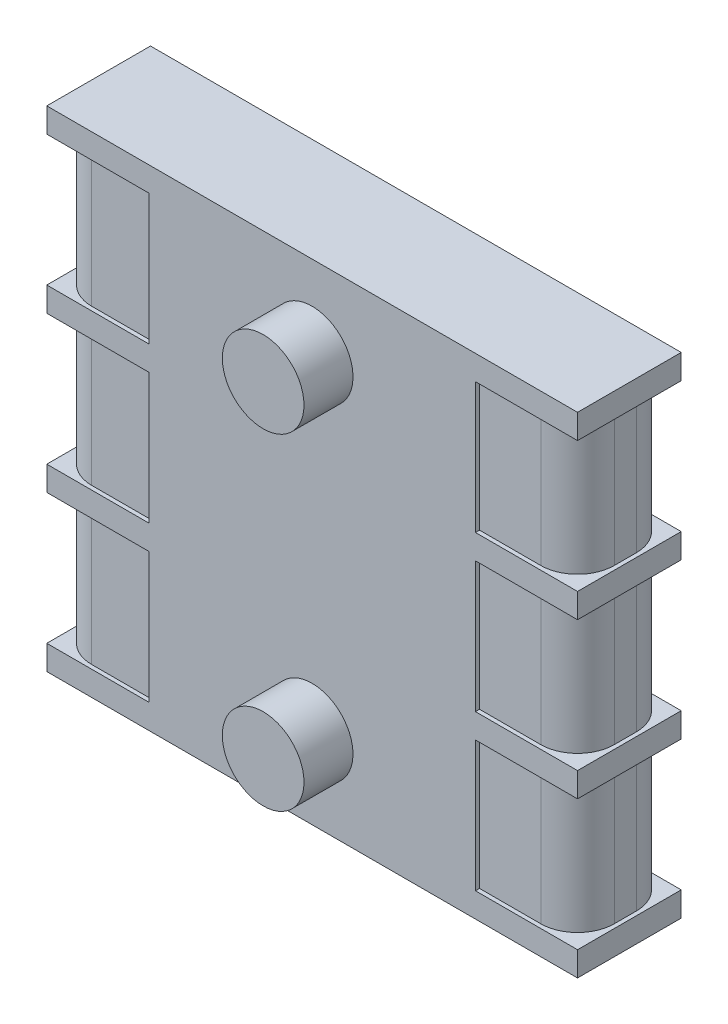
from build123d import *

# Parameters (mm, degrees)
SKETCH1_W           = 6.5
SKETCH1_H           = 1.27
BOSS_EXTRUDE1_DEPTH = 0.3
BOSS_EXTRUDE2_DEPTH = 1.6
BOSS_EXTRUDE3_START = 1.9
SKETCH1_2_W         = 6.5
SKETCH1_2_H         = 1.27
BOSS_EXTRUDE3_DEPTH = 0.3
BOSS_EXTRUDE4_START = 1.9
BOSS_EXTRUDE4_DEPTH = 1.6
BOSS_EXTRUDE5_START = 3.8
SKETCH1_3_W         = 6.5
SKETCH1_3_H         = 1.27
BOSS_EXTRUDE5_DEPTH = 0.3
BOSS_EXTRUDE6_START = 3.8
BOSS_EXTRUDE6_DEPTH = 1.6
BOSS_EXTRUDE7_START = 5.7
SKETCH1_4_W         = 6.5
SKETCH1_4_H         = 1.27
BOSS_EXTRUDE7_DEPTH = 0.3
SKETCH3_W           = 4
SKETCH3_H           = 5.4
BOSS_EXTRUDE8_DEPTH = 0.2
SKETCH4_R           = 0.5
BOSS_EXTRUDE9_DEPTH = 0.6


with BuildPart() as part:
    # Sketch1 → Boss-Extrude1 (new body)
    with BuildSketch(Plane(origin=(0, 0, 0), x_dir=(1, 0, 0), z_dir=(0, 1, 0))):
        with Locations((3.25, 0.635)):
            Rectangle(SKETCH1_W, SKETCH1_H)
    extrude(amount=BOSS_EXTRUDE1_DEPTH)

    # Sketch2 → Boss-Extrude2 (add)
    with BuildSketch(Plane(origin=(0, 0.3, 0), x_dir=(1, 0, 0), z_dir=(0, 1, 0))):
        with BuildLine():
            Line((1.25, 0.2), (0.5, 0.2))
            ThreePointArc((0.5, 0.2), (0.287867966, 0.287867966), (0.2, 0.5))
            Line((0.2, 0.5), (0.2, 0.77))
            ThreePointArc((0.2, 0.77), (0.287867966, 0.982132034), (0.5, 1.07))
            Line((0.5, 1.07), (6, 1.07))
            ThreePointArc((6, 1.07), (6.212132034, 0.982132034), (6.3, 0.77))
            Line((6.3, 0.77), (6.3, 0.5))
            ThreePointArc((6.3, 0.5), (6.212132034, 0.287867966), (6, 0.2))
            Line((6, 0.2), (5.25, 0.2))
            Line((5.25, 0.2), (5.25, 0.05))
            Line((5.25, 0.05), (6, 0.05))
            ThreePointArc((6, 0.05), (6.318198052, 0.181801948), (6.45, 0.5))
            Line((6.45, 0.5), (6.45, 0.77))
            ThreePointArc((6.45, 0.77), (6.318198052, 1.088198052), (6, 1.22))
            Line((6, 1.22), (0.5, 1.22))
            ThreePointArc((0.5, 1.22), (0.181801948, 1.088198052), (0.05, 0.77))
            Line((0.05, 0.77), (0.05, 0.5))
            ThreePointArc((0.05, 0.5), (0.181801948, 0.181801948), (0.5, 0.05))
            Line((0.5, 0.05), (1.25, 0.05))
            Line((1.25, 0.05), (1.25, 0.2))
        make_face()
    extrude(amount=BOSS_EXTRUDE2_DEPTH)

    # Sketch1_2 → Boss-Extrude3 (add)
    with BuildSketch(Plane(origin=(0, 0, 0), x_dir=(1, 0, 0), z_dir=(0, 1, 0)).offset(BOSS_EXTRUDE3_START)):
        with Locations((3.25, 0.635)):
            Rectangle(SKETCH1_2_W, SKETCH1_2_H)
    extrude(amount=BOSS_EXTRUDE3_DEPTH)

    # Sketch2_3 → Boss-Extrude4 (add)
    with BuildSketch(Plane(origin=(0, 0.3, 0), x_dir=(1, 0, 0), z_dir=(0, 1, 0)).offset(BOSS_EXTRUDE4_START)):
        with BuildLine():
            Line((1.25, 0.2), (0.5, 0.2))
            ThreePointArc((0.5, 0.2), (0.287867966, 0.287867966), (0.2, 0.5))
            Line((0.2, 0.5), (0.2, 0.77))
            ThreePointArc((0.2, 0.77), (0.287867966, 0.982132034), (0.5, 1.07))
            Line((0.5, 1.07), (6, 1.07))
            ThreePointArc((6, 1.07), (6.212132034, 0.982132034), (6.3, 0.77))
            Line((6.3, 0.77), (6.3, 0.5))
            ThreePointArc((6.3, 0.5), (6.212132034, 0.287867966), (6, 0.2))
            Line((6, 0.2), (5.25, 0.2))
            Line((5.25, 0.2), (5.25, 0.05))
            Line((5.25, 0.05), (6, 0.05))
            ThreePointArc((6, 0.05), (6.318198052, 0.181801948), (6.45, 0.5))
            Line((6.45, 0.5), (6.45, 0.77))
            ThreePointArc((6.45, 0.77), (6.318198052, 1.088198052), (6, 1.22))
            Line((6, 1.22), (0.5, 1.22))
            ThreePointArc((0.5, 1.22), (0.181801948, 1.088198052), (0.05, 0.77))
            Line((0.05, 0.77), (0.05, 0.5))
            ThreePointArc((0.05, 0.5), (0.181801948, 0.181801948), (0.5, 0.05))
            Line((0.5, 0.05), (1.25, 0.05))
            Line((1.25, 0.05), (1.25, 0.2))
        make_face()
    extrude(amount=BOSS_EXTRUDE4_DEPTH)

    # Sketch1_3 → Boss-Extrude5 (add)
    with BuildSketch(Plane(origin=(0, 0, 0), x_dir=(1, 0, 0), z_dir=(0, 1, 0)).offset(BOSS_EXTRUDE5_START)):
        with Locations((3.25, 0.635)):
            Rectangle(SKETCH1_3_W, SKETCH1_3_H)
    extrude(amount=BOSS_EXTRUDE5_DEPTH)

    # Sketch2_4 → Boss-Extrude6 (add)
    with BuildSketch(Plane(origin=(0, 0.3, 0), x_dir=(1, 0, 0), z_dir=(0, 1, 0)).offset(BOSS_EXTRUDE6_START)):
        with BuildLine():
            Line((1.25, 0.2), (0.5, 0.2))
            ThreePointArc((0.5, 0.2), (0.287867966, 0.287867966), (0.2, 0.5))
            Line((0.2, 0.5), (0.2, 0.77))
            ThreePointArc((0.2, 0.77), (0.287867966, 0.982132034), (0.5, 1.07))
            Line((0.5, 1.07), (6, 1.07))
            ThreePointArc((6, 1.07), (6.212132034, 0.982132034), (6.3, 0.77))
            Line((6.3, 0.77), (6.3, 0.5))
            ThreePointArc((6.3, 0.5), (6.212132034, 0.287867966), (6, 0.2))
            Line((6, 0.2), (5.25, 0.2))
            Line((5.25, 0.2), (5.25, 0.05))
            Line((5.25, 0.05), (6, 0.05))
            ThreePointArc((6, 0.05), (6.318198052, 0.181801948), (6.45, 0.5))
            Line((6.45, 0.5), (6.45, 0.77))
            ThreePointArc((6.45, 0.77), (6.318198052, 1.088198052), (6, 1.22))
            Line((6, 1.22), (0.5, 1.22))
            ThreePointArc((0.5, 1.22), (0.181801948, 1.088198052), (0.05, 0.77))
            Line((0.05, 0.77), (0.05, 0.5))
            ThreePointArc((0.05, 0.5), (0.181801948, 0.181801948), (0.5, 0.05))
            Line((0.5, 0.05), (1.25, 0.05))
            Line((1.25, 0.05), (1.25, 0.2))
        make_face()
    extrude(amount=BOSS_EXTRUDE6_DEPTH)

    # Sketch1_4 → Boss-Extrude7 (add)
    with BuildSketch(Plane(origin=(0, 0, 0), x_dir=(1, 0, 0), z_dir=(0, 1, 0)).offset(BOSS_EXTRUDE7_START)):
        with Locations((3.25, 0.635)):
            Rectangle(SKETCH1_4_W, SKETCH1_4_H)
    extrude(amount=BOSS_EXTRUDE7_DEPTH)

    # Sketch3 → Boss-Extrude8 (add)
    with BuildSketch(Plane.XY):
        with Locations((3.25, 3)):
            Rectangle(SKETCH3_W, SKETCH3_H)
    extrude(amount=-BOSS_EXTRUDE8_DEPTH)

    # Sketch4 → Boss-Extrude9 (add)
    with BuildSketch(Plane.XY):
        with Locations(Location((3.25, 5, 0), (0, 0, 180))):
            Circle(SKETCH4_R)
        with Locations(Location((3.25, 1, 0), (0, 0, 180))):
            Circle(SKETCH4_R)
    extrude(amount=BOSS_EXTRUDE9_DEPTH)


solid = part.part
